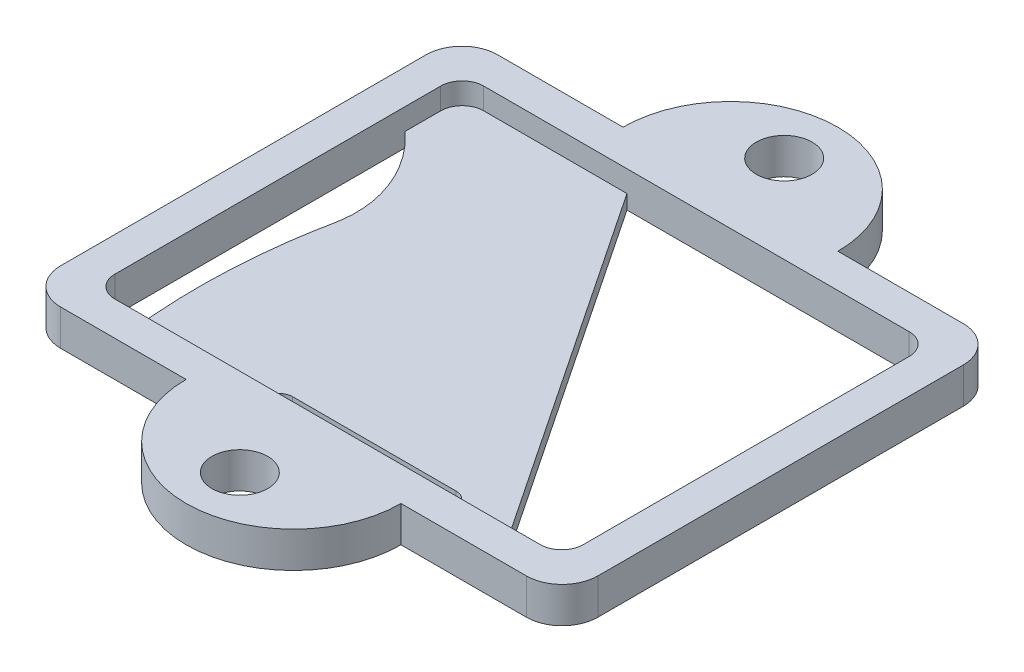
from build123d import *

# Parameters (mm, degrees)
SKETCH1_R           = 3.9
BOSS_EXTRUDE1_DEPTH = 5
CUT_EXTRUDE1_DEPTH  = 3
CUT_EXTRUDE2_DEPTH  = 3
FILLET1_R           = 5
FILLET2_R           = 3


with BuildPart() as part:
    # Sketch1 → Boss-Extrude1 (new body)
    with BuildSketch(Plane(origin=(0, 0, 0), x_dir=(1, 0, 0), z_dir=(0, 1, 0))):
        with BuildLine():
            ThreePointArc((-22.5, 61), (-37.5, 76), (-52.5, 61))
            Line((-52.5, 61), (-75, 61))
            Line((-75, 61), (-75, 0))
            Line((-75, 0), (-52.5, 0))
            ThreePointArc((-52.5, 0), (-37.5, -15), (-22.5, 0))
            Line((-22.5, 0), (0, 0))
            Line((0, 0), (0, 61))
            Line((0, 61), (-22.5, 61))
        make_face()
        with Locations((-37.5, 68.5)):
            Circle(SKETCH1_R, mode=Mode.SUBTRACT)
        with Locations((-37.5, -7.5)):
            Circle(SKETCH1_R, mode=Mode.SUBTRACT)
    extrude(amount=BOSS_EXTRUDE1_DEPTH)

    # Sketch2 → Cut-Extrude1 (cut)
    with BuildSketch(Plane(origin=(0, 5, 0), x_dir=(1, 0, 0), z_dir=(0, 1, 0))):
        Polygon((-5.840163934, 4.75), (-69.159836066, 56.25), (-70.2, 56.25), (-70.2, 4.75), align=None)
        Polygon((-4.8, 56.25), (-69.159836066, 56.25), (-5.840163934, 4.75), (-4.8, 4.75), align=None)
    extrude(amount=-CUT_EXTRUDE1_DEPTH, mode=Mode.SUBTRACT)

    # Sketch3 → Cut-Extrude2 (cut, through all)
    with BuildSketch(Plane(origin=(0, 2, 0), x_dir=(1, 0, 0), z_dir=(0, 1, 0))):
        with BuildLine():
            add(Edge.make_bspline(
                [(-70.2, 48.25), (-69.3360202, 47.393408535), (-68.484165296, 46.526885218)],
                knots=[0, 0, 0, 0.044512792, 0.044512792, 0.044512792], degree=2))
            Line((-70.2, 48.25), (-70.2, 4.75))
            Line((-70.2, 4.75), (-65.2, 4.75))
            add(Edge.make_bspline(
                [(-65.2, 4.75), (-66.281505433, 14.095378491), (-65.909161294, 23.268767529), (-64.082967584, 32.270167116)],
                knots=[0, 0, 0, 0, 0.780709758, 0.780709758, 0.780709758, 0.780709758], degree=3))
            add(Edge.make_bspline(
                [(-64.082967584, 32.270167116), (-64.075541276, 32.30677176), (-64.068090925, 32.343373559), (-64.060616532, 32.379972514)],
                knots=[0.780709758, 0.780709758, 0.780709758, 0.780709758, 0.783884554, 0.783884554, 0.783884554, 0.783884554], degree=3))
            add(Edge.make_bspline(
                [(-68.484165296, 46.526885218), (-65.083389168, 42.682237292), (-63.043469729, 37.485478449), (-64.060616531, 32.379972514)],
                knots=[0.136165996, 0.136165996, 0.136165996, 0.136165996, 0.993850371, 0.993850371, 0.993850371, 0.993850371], degree=3))
        make_face()
        Polygon((-12.8, 56.25), (-47.2, 56.25), (-12.8, 4.75), (-4.8, 4.75), (-4.8, 56.25), align=None)
        with BuildLine():
            Line((-23.141162666, 4.75), (-21.341162666, 4.75))
            Line((-21.341162666, 4.75), (-21.341162666, 6.55))
            ThreePointArc((-21.341162666, 6.55), (-21.86837046, 7.822792206), (-23.141162666, 8.35))
            Line((-23.141162666, 8.35), (-45.995816889, 8.35))
            ThreePointArc((-45.995816889, 8.35), (-47.268609095, 7.822792206), (-47.795816889, 6.55))
            Line((-47.795816889, 6.55), (-47.795816889, 4.75))
            Line((-47.795816889, 4.75), (-45.995816889, 4.75))
            Line((-45.995816889, 4.75), (-23.141162666, 4.75))
        make_face()
    extrude(amount=-CUT_EXTRUDE2_DEPTH, mode=Mode.SUBTRACT)

    # Fillet1
    fillet1_edges = [part.edges().sort_by_distance(p)[0] for p in [
        (-75, 2.5, -61),
        (0, 2.5, -61),
        (0, 2.5, 0),
        (-75, 2.5, 0),
    ]]
    fillet(fillet1_edges, radius=FILLET1_R)

    # Fillet2
    fillet2_edges = [part.edges().sort_by_distance(p)[0] for p in [
        (-70.2, 3.5, -56.25),
        (-4.8, 2.5, -56.25),
        (-4.8, 2.5, -4.75),
        (-70.2, 2.5, -4.75),
    ]]
    fillet(fillet2_edges, radius=FILLET2_R)


solid = part.part
